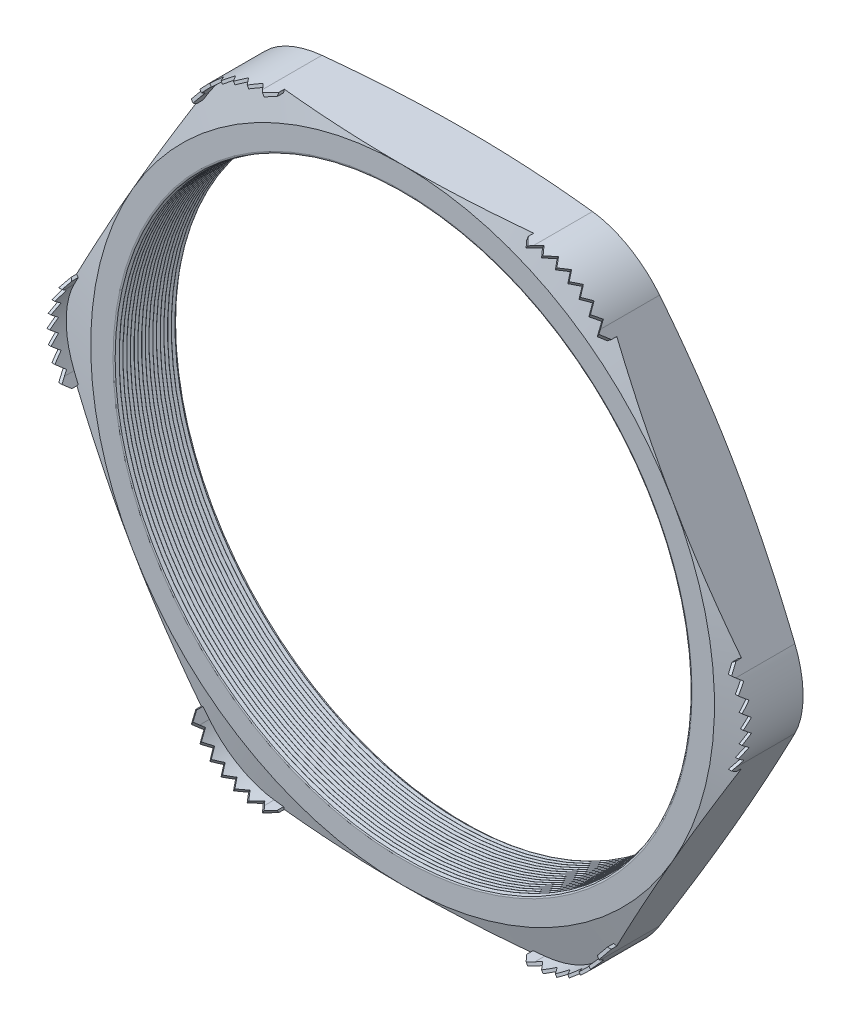
from build123d import *

# Parameters (mm, degrees)
SKETCH1_R          = 23.495
EXTRUDE1_DEPTH     = 5.08
FILLET1_R          = 6.35
FILLET3_R          = 0.2032
LPATTERN1_COUNT    = 17
LPATTERN1_PITCH    = 0.3048
SKETCH4_OUTSIDE_W  = 119.706
SKETCH4_OUTSIDE_H  = 113.772
SKETCH4_OUTSIDE_R  = 25.527
CUT_EXTRUDE1_DEPTH = 6.08
CUT_EXTRUDE1_DRAFT = -75
SKETCH5_OUTSIDE_W  = 119.706
SKETCH5_OUTSIDE_H  = 113.772
SKETCH5_OUTSIDE_R  = 25.527
CUT_EXTRUDE2_DEPTH = 6.0800001
CUT_EXTRUDE2_DRAFT = -75
EXTRUDE2_START     = -0.794923
EXTRUDE2_DEPTH     = 2.445923
CUT_EXTRUDE4_DEPTH = 10.3406966
CIRPATTERN1_COUNT  = 6
CIRPATTERN2_COUNT  = 6


with BuildPart() as part:
    # Sketch1 → Extrude1 (new body)
    with BuildSketch(Plane.XY):
        Polygon((-29.476040643, 0), (-14.738020322, -25.527), (14.738020322, -25.527), (29.476040643, 0), (14.738020322, 25.527), (-14.738020322, 25.527), align=None)
        Circle(SKETCH1_R, mode=Mode.SUBTRACT)
    extrude(amount=EXTRUDE1_DEPTH)

    # Fillet1
    fillet1_edges = [part.edges().sort_by_distance(p)[0] for p in [
        (29.476040643, 0, 2.54),
        (14.738020322, -25.527, 2.54),
        (-14.738020322, -25.527, 2.54),
        (-29.476040643, 0, 2.54),
        (-14.738020322, 25.527, 2.54),
        (14.738020322, 25.527, 2.54),
    ]]
    fillet(fillet1_edges, radius=FILLET1_R)

    # Fillet3
    fillet3_edges = [part.edges().sort_by_distance(p)[0] for p in [
        (-23.495, 0, 0),
        (-23.495, 0, 5.08),
    ]]
    fillet(fillet3_edges, radius=FILLET3_R)

    # Sketch3 → Cut-Revolve1 (revolve, cut)
    with BuildSketch(Plane(origin=(0, 0, 0), x_dir=(1, 0, 0), z_dir=(0, 1, 0))):
        Polygon((-23.495, -5.08), (-23.495, -4.786706063), (-23.749, -4.933353032), align=None)
    cut_revolve1 = revolve(axis=Axis((0, 0, 5.08), (0, 0, -1)), mode=Mode.SUBTRACT)

    # LPattern1: Cut-Revolve1 ×17
    with Locations(*[(0, 0, -i * LPATTERN1_PITCH) for i in range(1, LPATTERN1_COUNT)]):
        add(cut_revolve1, mode=Mode.SUBTRACT)


with BuildPart() as cut_extrude1_tool:
    # Sketch4 outside → Cut-Extrude1 (with draft: the straight prism first)
    with BuildSketch(Plane(origin=(0, 0, 0), x_dir=(-1, 0, 0), z_dir=(0, 0, -1))):
        Rectangle(SKETCH4_OUTSIDE_W, SKETCH4_OUTSIDE_H)
        Circle(SKETCH4_OUTSIDE_R, mode=Mode.SUBTRACT)
    extrude(amount=-CUT_EXTRUDE1_DEPTH)
    # Cut-Extrude1: the draft: its side faces are tilted about the plane it starts from
    cut_extrude1_sides = [cut_extrude1_tool.faces().sort_by_distance(p)[0] for p in [
        (0, -56.886, 3.04),
        (-59.853, 0, 3.04),
        (0, 56.886, 3.04),
        (59.853, 0, 3.04),
        (25.527, 0, 3.04),
    ]]
    draft(cut_extrude1_sides, Plane(origin=(0, 0, 0), x_dir=(-1, 0, 0), z_dir=(0, 0, -1)), CUT_EXTRUDE1_DRAFT)


with BuildPart() as part_1:
    add(part.part)

    # Cut-Extrude1: cut by cut_extrude1_tool
    add(cut_extrude1_tool.part, mode=Mode.SUBTRACT)


with BuildPart() as cut_extrude2_tool:
    # Sketch5 outside → Cut-Extrude2 (with draft: the straight prism first)
    with BuildSketch(Plane.XY.offset(5.08)):
        Rectangle(SKETCH5_OUTSIDE_W, SKETCH5_OUTSIDE_H)
        Circle(SKETCH5_OUTSIDE_R, mode=Mode.SUBTRACT)
    extrude(amount=-CUT_EXTRUDE2_DEPTH)
    # Cut-Extrude2: the draft: its side faces are tilted about the plane it starts from
    cut_extrude2_sides = [cut_extrude2_tool.faces().sort_by_distance(p)[0] for p in [
        (0, -56.886, 2.03999995),
        (59.853, 0, 2.03999995),
        (0, 56.886, 2.03999995),
        (-59.853, 0, 2.03999995),
        (-25.527, 0, 2.03999995),
    ]]
    draft(cut_extrude2_sides, Plane.XY.offset(5.08), CUT_EXTRUDE2_DRAFT)


with BuildPart() as part_2:
    add(part_1.part)

    # Cut-Extrude2: cut by cut_extrude2_tool
    add(cut_extrude2_tool.part, mode=Mode.SUBTRACT)

    # Sketch2 → Extrude2 (add)
    with BuildSketch(Plane.XY.offset(5.08).offset(EXTRUDE2_START)):
        with BuildLine():
            Line((-11.071846112, 25.527), (-10.208246112, 25.527))
            Line((-10.208246112, 25.527), (-10.208246112, 25.2984))
            Line((-10.208246112, 25.2984), (-11.071846112, 25.2984))
            ThreePointArc((-11.071846112, 25.2984), (-14.132546112, 24.478287907), (-16.373134019, 22.2377))
            Line((-16.373134019, 22.2377), (-16.804934019, 21.489800461))
            Line((-16.804934019, 21.489800461), (-17.002907426, 21.604100461))
            Line((-17.002907426, 21.604100461), (-16.571107426, 22.352))
            ThreePointArc((-16.571107426, 22.352), (-14.246846112, 24.676261314), (-11.071846112, 25.527))
        make_face()
    extrude2 = extrude(amount=EXTRUDE2_DEPTH)

    # Sketch7 → Cut-Extrude4 (cut, through all)
    with BuildSketch(Plane(origin=(-13.506590066, 23.394100231, 0), x_dir=(0.866025404, 0.5, 0), z_dir=(0.5, -0.866025404, 0))):
        Polygon((-3.922899539, 4.99745), (-3.364099539, 5.69087), (-2.805299539, 4.99745), (-2.2352, 5.69087), (-1.6764, 4.99745), (-1.1176, 5.69087), (-0.5588, 4.99745), (0, 5.69087), (0.5588, 4.99745), (1.1176, 5.69087), (1.6764, 4.99745), (2.2352, 5.69087), (2.794, 4.99745), (3.364099539, 5.69087), (3.922899539, 4.99745), (3.922899539, 6.731), (-3.922899539, 6.731), align=None)
    cut_extrude4 = extrude(amount=-CUT_EXTRUDE4_DEPTH, mode=Mode.SUBTRACT)

    # CirPattern1: Extrude2 ×6 about axis
    cirpattern1_axis = Axis((0, 0, 0), (0, 0, 1))
    for i in range(1, CIRPATTERN1_COUNT):
        add(extrude2.rotate(cirpattern1_axis, i * 360 / CIRPATTERN1_COUNT))

    # CirPattern2: Cut-Extrude4 ×6 about axis
    cirpattern2_axis = Axis((0, 0, 0), (0, 0, 1))
    for i in range(1, CIRPATTERN2_COUNT):
        add(cut_extrude4.rotate(cirpattern2_axis, i * 360 / CIRPATTERN2_COUNT), mode=Mode.SUBTRACT)


solid = part_2.part
